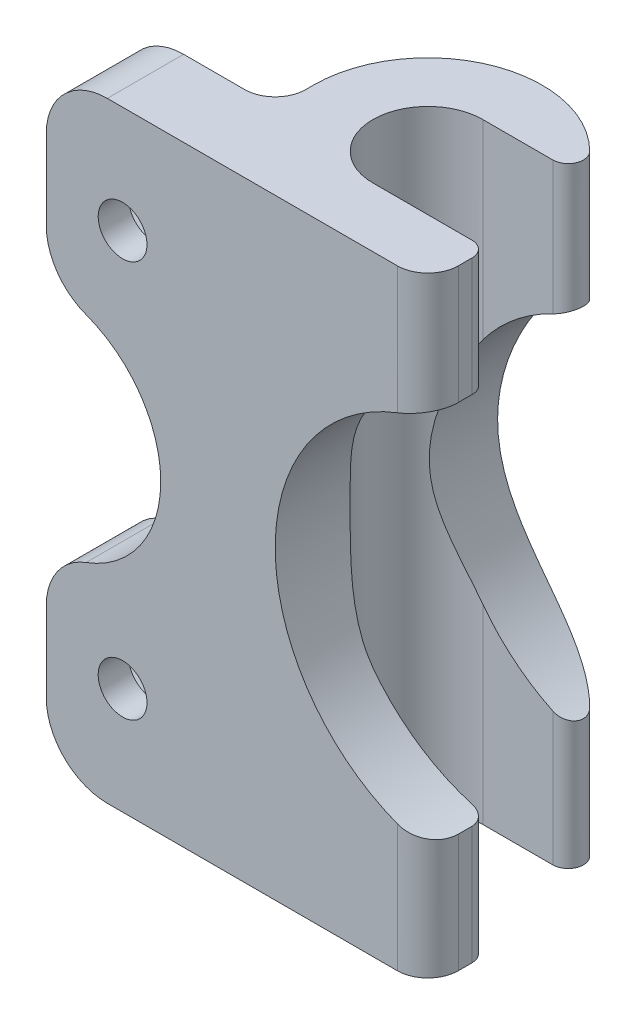
from build123d import *

# Parameters (mm, degrees)
SALIENTE_EXTRUIR1_DEPTH    = 40
CROQUIS2_R                 = 1.6
CORTAR_EXTRUIR1_DEPTH      = 6
CORTAR_EXTRUIR2_DEPTH      = 3
CORTAR_EXTRUIR3_DEPTH      = 6
REDONDEO1_R                = 4
REDONDEO2_R                = 2
REDONDEO3_R                = 1
CROQUIS5_R                 = 12.5
CORTAR_EXTRUIR4_DEPTH      = 8.5
CORTAR_EXTRUIR4_DEPTH_BACK = 8.5


with BuildPart() as part:
    # Croquis1 → Saliente-Extruir1 (new body)
    with BuildSketch(Plane(origin=(0, 0, 0), x_dir=(1, 0, 0), z_dir=(0, 1, 0))):
        with BuildLine():
            Line((-17.5, -7.5), (7.5, -7.5))
            Line((7.5, -7.5), (7.5, -3.6))
            Line((7.5, -3.6), (0, -3.6))
            ThreePointArc((0, -3.6), (-3.6, 0), (0, 3.6))
            Line((0, 3.6), (6.57951366, 3.6))
            ThreePointArc((6.57951366, 3.6), (-1.857908441, 7.266235354), (-7.5, 0))
            Line((-7.5, 0), (-7.5, -2.5))
            Line((-7.5, -2.5), (-17.5, -2.5))
            Line((-17.5, -2.5), (-17.5, -7.5))
        make_face()
    extrude(amount=SALIENTE_EXTRUIR1_DEPTH)

    # Croquis2 → Cortar-Extruir1 (cut, through all)
    with BuildSketch(Plane(origin=(0, 0, 2.5), x_dir=(-1, 0, 0), z_dir=(0, 0, -1))):
        with Locations((12.5, 7)):
            Circle(CROQUIS2_R)
        with Locations((12.5, 33)):
            Circle(CROQUIS2_R)
    extrude(amount=-CORTAR_EXTRUIR1_DEPTH, mode=Mode.SUBTRACT)

    # Croquis3 → Cortar-Extruir2 (cut)
    with BuildSketch(Plane(origin=(0, 0, 2.5), x_dir=(-1, 0, 0), z_dir=(0, 0, -1))):
        Polygon((15.3, 31.383419246), (15.3, 34.616580754), (12.5, 36.233161507), (9.7, 34.616580754), (9.7, 31.383419246), (12.5, 29.766838493), align=None)
        Polygon((12.5, 10.233161507), (15.3, 8.616580754), (15.3, 5.383419246), (12.5, 3.766838493), (9.7, 5.383419246), (9.7, 8.616580754), align=None)
    extrude(amount=-CORTAR_EXTRUIR2_DEPTH, mode=Mode.SUBTRACT)

    # Croquis4 → Cortar-Extruir3 (cut, through all)
    with BuildSketch(Plane(origin=(0, 0, 2.5), x_dir=(-1, 0, 0), z_dir=(0, 0, -1))):
        with BuildLine():
            Line((17.5, 27.5), (17.5, 12.5))
            ThreePointArc((17.5, 12.5), (10, 20), (17.5, 27.5))
        make_face()
    extrude(amount=-CORTAR_EXTRUIR3_DEPTH, mode=Mode.SUBTRACT)

    # Redondeo1
    redondeo1_edges = [part.edges().sort_by_distance(p)[0] for p in [
        (-17.5, 40, 5),
        (-17.5, 12.5, 5),
        (-17.5, 27.5, 5),
        (-17.5, 0, 5),
    ]]
    fillet(redondeo1_edges, radius=REDONDEO1_R)

    # Redondeo2
    redondeo2_edges = [part.edges().sort_by_distance(p)[0] for p in [
        (7.5, 20, 7.5),
        (-7.5, 20, 2.5),
    ]]
    fillet(redondeo2_edges, radius=REDONDEO2_R)

    # Redondeo3
    redondeo3_edges = [part.edges().sort_by_distance(p)[0] for p in [
        (7.5, 20, 3.6),
        (6.57951366, 20, -3.6),
    ]]
    fillet(redondeo3_edges, radius=REDONDEO3_R)

    # Croquis5 → Cortar-Extruir4 (cut, two sides)
    with BuildSketch(Plane.XY) as cortar_extruir4_sk:
        with Locations((10, 20)):
            Circle(CROQUIS5_R)
    extrude(amount=CORTAR_EXTRUIR4_DEPTH, mode=Mode.SUBTRACT)
    extrude(cortar_extruir4_sk.sketch, amount=-CORTAR_EXTRUIR4_DEPTH_BACK, mode=Mode.SUBTRACT)


solid = part.part
